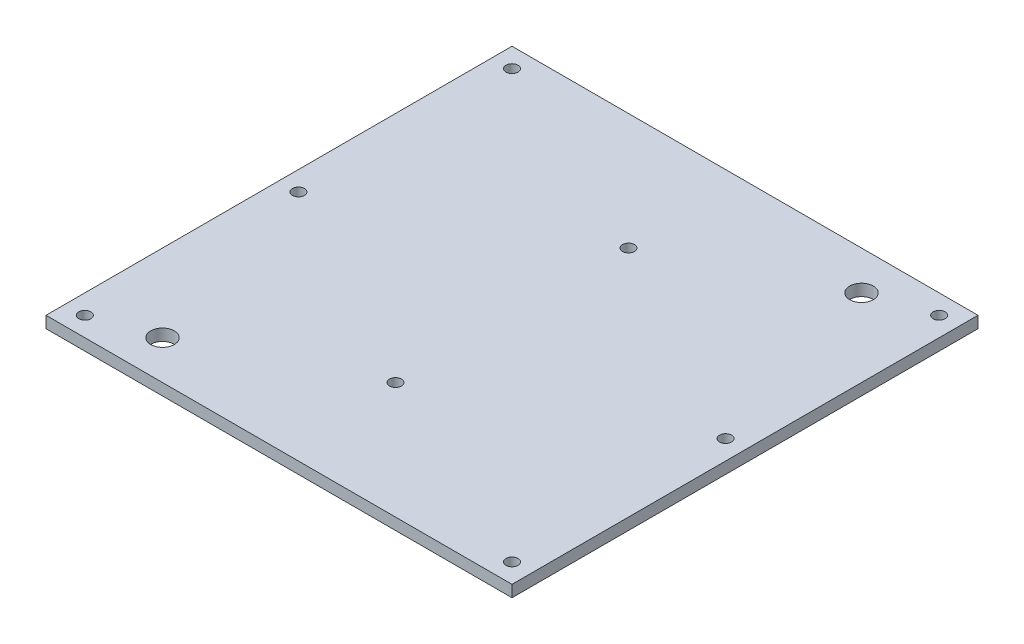
from build123d import *

# Parameters (mm, degrees)
SKETCH1_W           = 120
SKETCH1_H           = 120
SKETCH1_R           = 1.55
SKETCH1_R_2         = 3.05
BOSS_EXTRUDE1_DEPTH = 3


with BuildPart() as part:
    # Sketch1 → Boss-Extrude1 (new body)
    with BuildSketch(Plane(origin=(0, 0, 0), x_dir=(1, 0, 0), z_dir=(0, 1, 0))):
        Rectangle(SKETCH1_W, SKETCH1_H)
        with Locations((0, 30)):
            Circle(SKETCH1_R, mode=Mode.SUBTRACT)
        with Locations((0, -30)):
            Circle(SKETCH1_R, mode=Mode.SUBTRACT)
        with Locations((-55, -55)):
            Circle(SKETCH1_R, mode=Mode.SUBTRACT)
        with Locations((55, -55)):
            Circle(SKETCH1_R, mode=Mode.SUBTRACT)
        with Locations((55, 55)):
            Circle(SKETCH1_R, mode=Mode.SUBTRACT)
        with Locations((-55, 55)):
            Circle(SKETCH1_R, mode=Mode.SUBTRACT)
        with Locations((-55, 0)):
            Circle(SKETCH1_R, mode=Mode.SUBTRACT)
        with Locations((55, 0)):
            Circle(SKETCH1_R, mode=Mode.SUBTRACT)
        with Locations((-40, -50)):
            Circle(SKETCH1_R_2, mode=Mode.SUBTRACT)
        with Locations((40, 50)):
            Circle(SKETCH1_R_2, mode=Mode.SUBTRACT)
    extrude(amount=BOSS_EXTRUDE1_DEPTH)


solid = part.part
